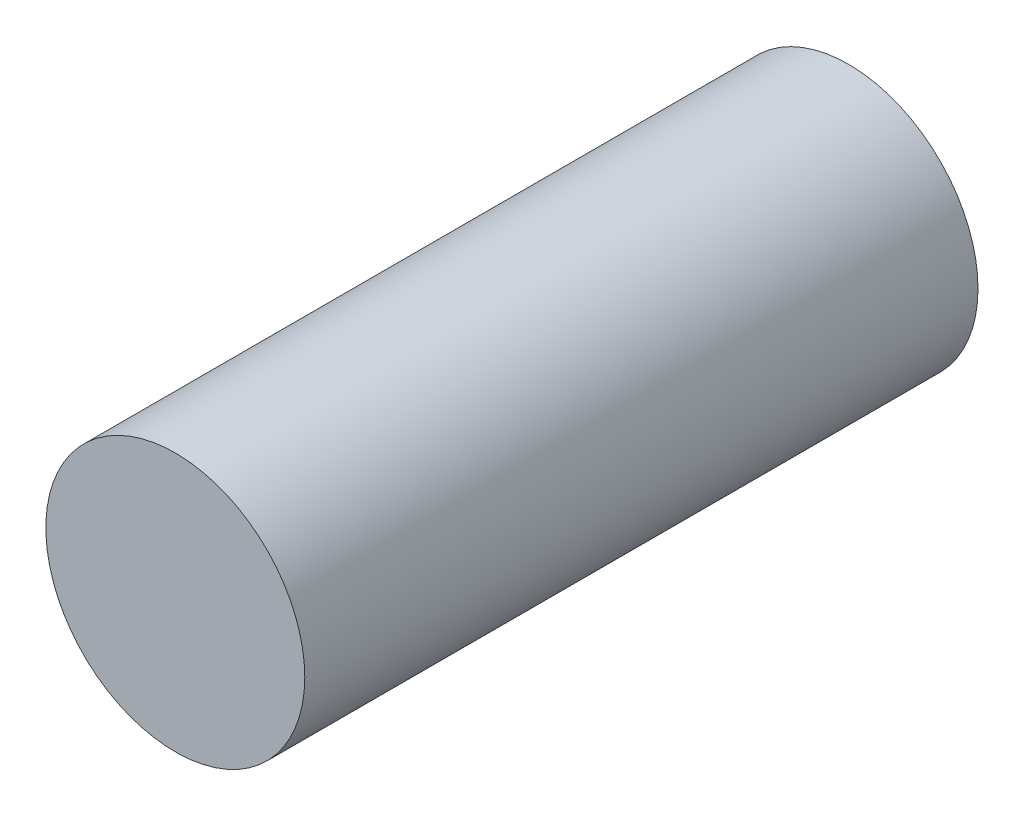
from build123d import *

# Parameters (mm, degrees)
SKETCH1_R           = 5
BOSS_EXTRUDE1_DEPTH = 26


with BuildPart() as part:
    # Sketch1 → Boss-Extrude1 (new body)
    with BuildSketch(Plane.XY):
        Circle(SKETCH1_R)
    extrude(amount=BOSS_EXTRUDE1_DEPTH)


solid = part.part
